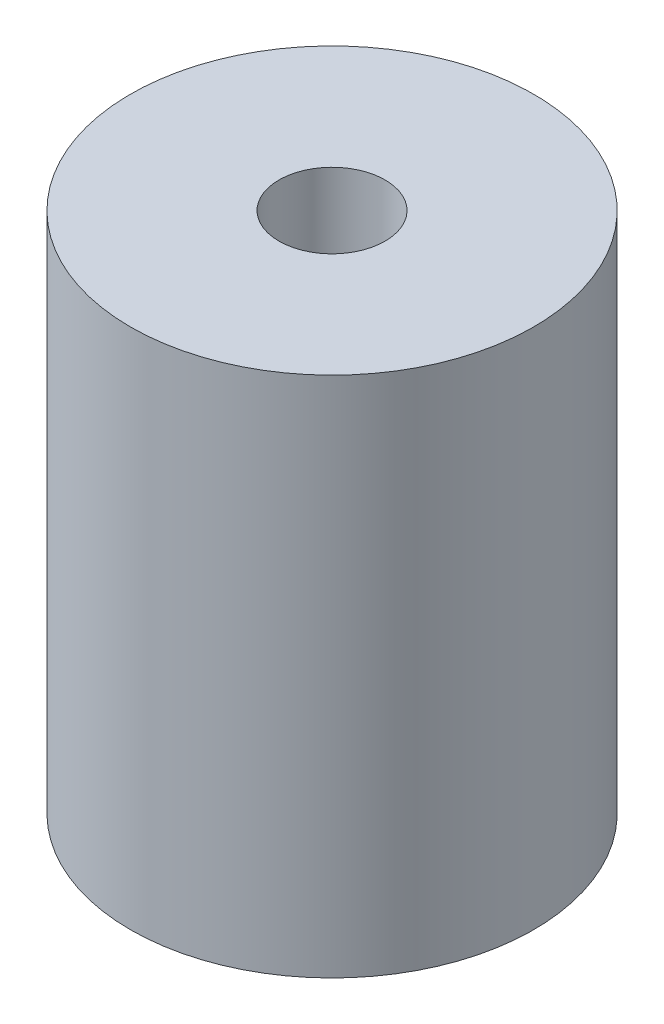
from build123d import *

# Parameters (mm, degrees)
SKETCH1_R           = 9.5
COUPLING_BODY_DEPTH = 24.6
F_5MM_HOLE_REACH    = 26.6
SKETCH2_R           = 2.5
SKETCH3_R           = 4
F_8_MM_HOLE_DEPTH   = 17.25


with BuildPart() as part:
    # Sketch1 → coupling body (new body)
    with BuildSketch(Plane(origin=(0, 0, 0), x_dir=(1, 0, 0), z_dir=(0, 1, 0))):
        Circle(SKETCH1_R)
    extrude(amount=COUPLING_BODY_DEPTH)

    # Sketch2 → 5mm hole (cut, up to next)
    with BuildSketch(Plane(origin=(0, 24.6, 0), x_dir=(1, 0, 0), z_dir=(0, 1, 0)), mode=Mode.PRIVATE) as f_5mm_hole_sk1:
        Circle(SKETCH2_R)
    f_5mm_hole_tool1 = extrude(f_5mm_hole_sk1.sketch, amount=-F_5MM_HOLE_REACH, mode=Mode.PRIVATE) & part.part
    add(f_5mm_hole_tool1.solids().sort_by_distance((0, 24.6, 0))[0], mode=Mode.SUBTRACT)

    # Sketch3 → 8 mm hole (cut)
    with BuildSketch(Plane.XZ):
        Circle(SKETCH3_R)
    extrude(amount=-F_8_MM_HOLE_DEPTH, mode=Mode.SUBTRACT)


solid = part.part
